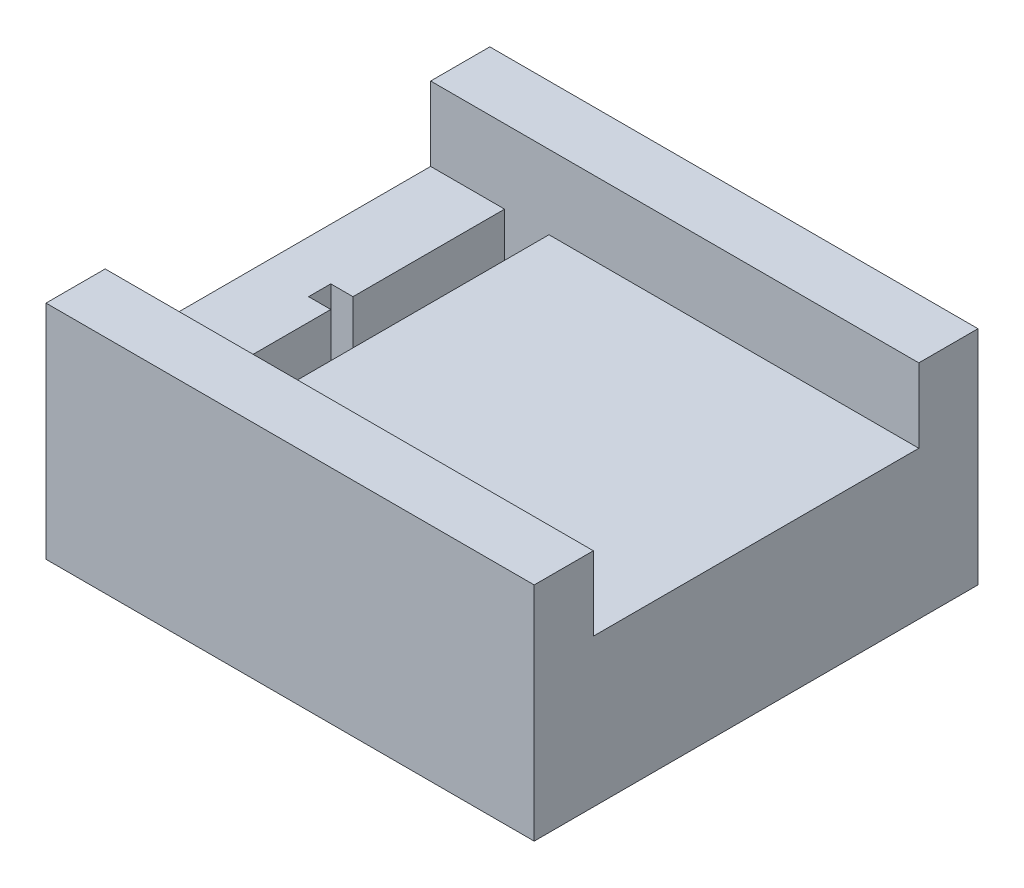
from build123d import *

# Parameters (mm, degrees)
SKETCH1_W           = 3
SKETCH1_H           = 22
BOSS_EXTRUDE3_DEPTH = 3
SKETCH1_6_W         = 25
SKETCH1_6_H         = 22
SKETCH1_6_W_2       = 5
BOSS_EXTRUDE4_DEPTH = 10
SKETCH1_7_W         = 33
SKETCH1_7_H         = 4
BOSS_EXTRUDE5_DEPTH = 15
SKETCH6_W           = 1.5
SKETCH6_H           = 1.5
CUT_EXTRUDE1_DEPTH  = 6


with BuildPart() as part:
    # Sketch1 → Boss-Extrude3 (new body)
    with BuildSketch(Plane(origin=(0, 0, 0), x_dir=(1, 0, 0), z_dir=(0, 1, 0))):
        with Locations((-14, 0)):
            Rectangle(SKETCH1_W, SKETCH1_H)
    extrude(amount=BOSS_EXTRUDE3_DEPTH)

    # Sketch1_6 → Boss-Extrude4 (add)
    with BuildSketch(Plane(origin=(0, 0, 0), x_dir=(1, 0, 0), z_dir=(0, 1, 0))):
        Rectangle(SKETCH1_6_W, SKETCH1_6_H)
        with Locations((-18, 0)):
            Rectangle(SKETCH1_6_W_2, SKETCH1_6_H)
    extrude(amount=BOSS_EXTRUDE4_DEPTH)

    # Sketch1_7 → Boss-Extrude5 (add)
    with BuildSketch(Plane(origin=(0, 0, 0), x_dir=(1, 0, 0), z_dir=(0, 1, 0))):
        with Locations((-4, -13)):
            Rectangle(SKETCH1_7_W, SKETCH1_7_H)
        with Locations((-4, 13)):
            Rectangle(SKETCH1_7_W, SKETCH1_7_H)
    extrude(amount=BOSS_EXTRUDE5_DEPTH)

    # Sketch6 → Cut-Extrude1 (cut)
    with BuildSketch(Plane(origin=(0, 10, 0), x_dir=(1, 0, 0), z_dir=(0, 1, 0))):
        with Locations((-16.25, 0)):
            Rectangle(SKETCH6_W, SKETCH6_H)
    extrude(amount=-CUT_EXTRUDE1_DEPTH, mode=Mode.SUBTRACT)


solid = part.part
